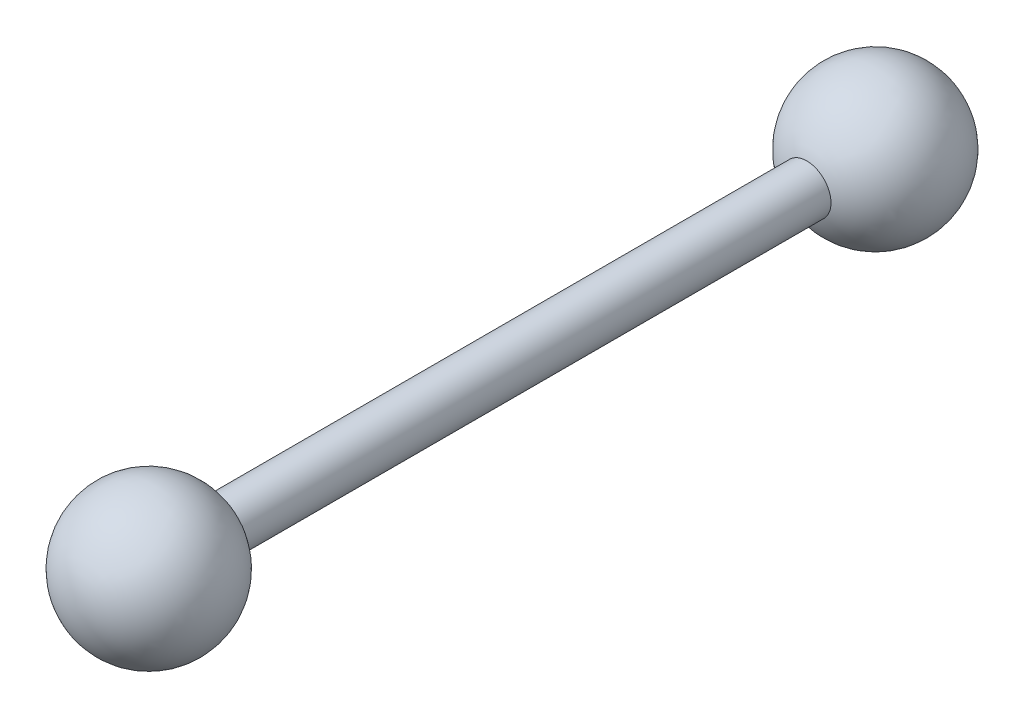
from build123d import *


with BuildPart() as part:
    # Sketch1 → Revolve1 (revolve)
    with BuildSketch(Plane(origin=(0, 0, 0), x_dir=(1, 0, 0), z_dir=(0, 1, 0))):
        with BuildLine():
            Line((0, 90), (0, -90))
            ThreePointArc((0, -90), (14.783978395, -77.536529681), (5, -60.857864376))
            Line((5, -60.857864376), (5, 60.857864376))
            ThreePointArc((5, 60.857864376), (14.783978395, 77.536529681), (0, 90))
        make_face()
    revolve(axis=Axis((0, 0, -90), (0, 0, 1)))


solid = part.part
